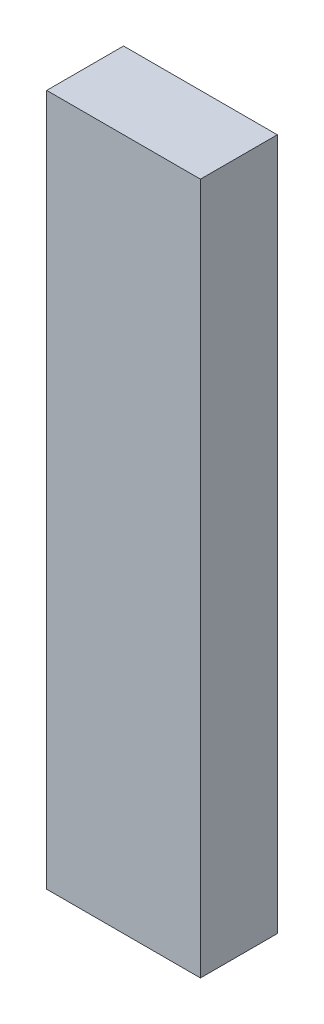
from build123d import *

# Parameters (mm, degrees)
ESQUISSE1_W      = 10
ESQUISSE1_H      = 45
EXTRUSION1_DEPTH = 5


with BuildPart() as part:
    # Esquisse1 → Extrusion1 (new body)
    with BuildSketch(Plane.XY):
        with Locations((5, 22.5)):
            Rectangle(ESQUISSE1_W, ESQUISSE1_H)
    extrude(amount=EXTRUSION1_DEPTH)


solid = part.part
